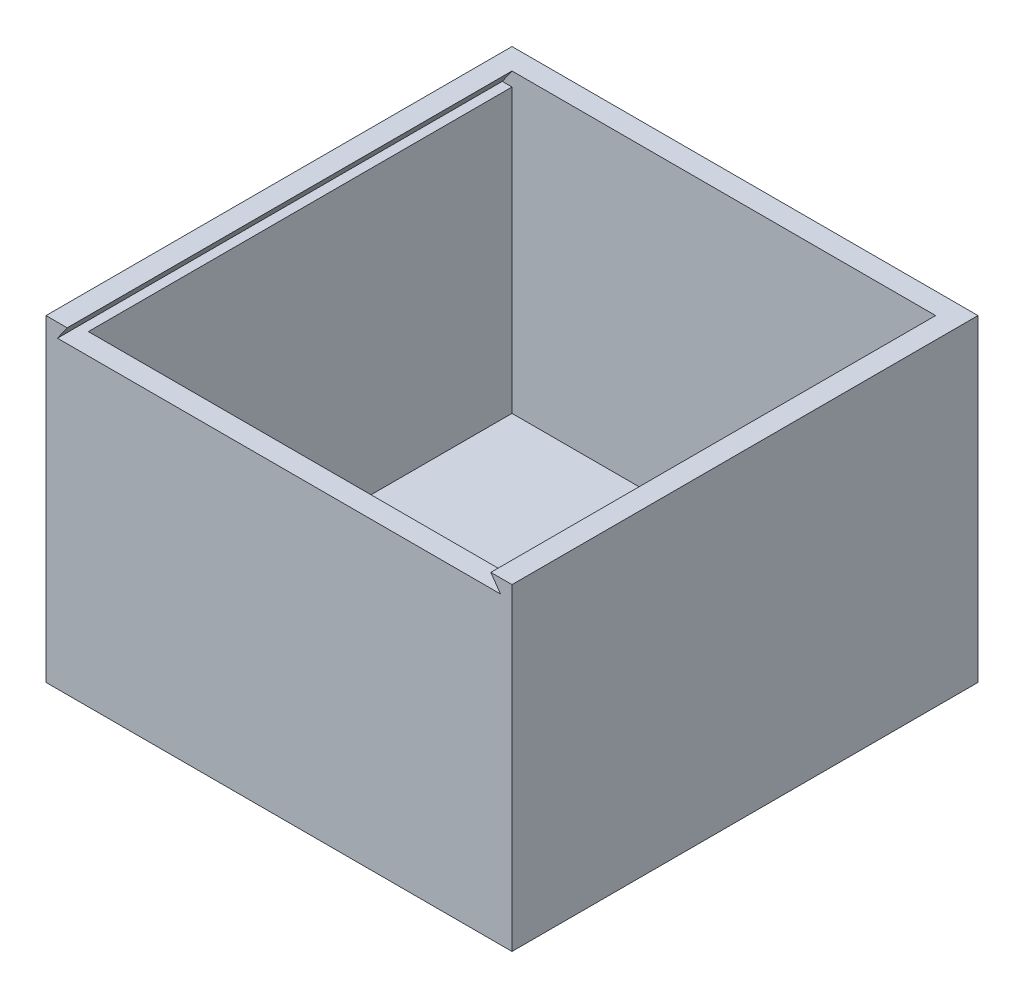
from build123d import *

# Parameters (mm, degrees)
SKETCH1_W           = 110
SKETCH1_H           = 110
BOSS_EXTRUDE1_DEPTH = 75
SKETCH2_W           = 100
SKETCH2_H           = 100
CUT_EXTRUDE2_DEPTH  = 70
CUT_EXTRUDE3_START  = -105
CUT_EXTRUDE3_DEPTH  = 105


with BuildPart() as part:
    # Sketch1 → Boss-Extrude1 (new body)
    with BuildSketch(Plane(origin=(0, 0, 0), x_dir=(1, 0, 0), z_dir=(0, 1, 0))):
        Rectangle(SKETCH1_W, SKETCH1_H)
    extrude(amount=BOSS_EXTRUDE1_DEPTH)

    # Sketch2 → Cut-Extrude2 (cut)
    with BuildSketch(Plane(origin=(0, 75, 0), x_dir=(1, 0, 0), z_dir=(0, 1, 0))):
        Rectangle(SKETCH2_W, SKETCH2_H)
    extrude(amount=-CUT_EXTRUDE2_DEPTH, mode=Mode.SUBTRACT)

    # Sketch4 → Cut-Extrude3 (cut)
    with BuildSketch(Plane.XY.offset(55).offset(CUT_EXTRUDE3_START)):
        Polygon((50, 75), (52.294305745, 71.723391823), (-52.294305745, 71.723391823), (-50, 75), align=None)
    extrude(amount=CUT_EXTRUDE3_DEPTH, mode=Mode.SUBTRACT)


solid = part.part
